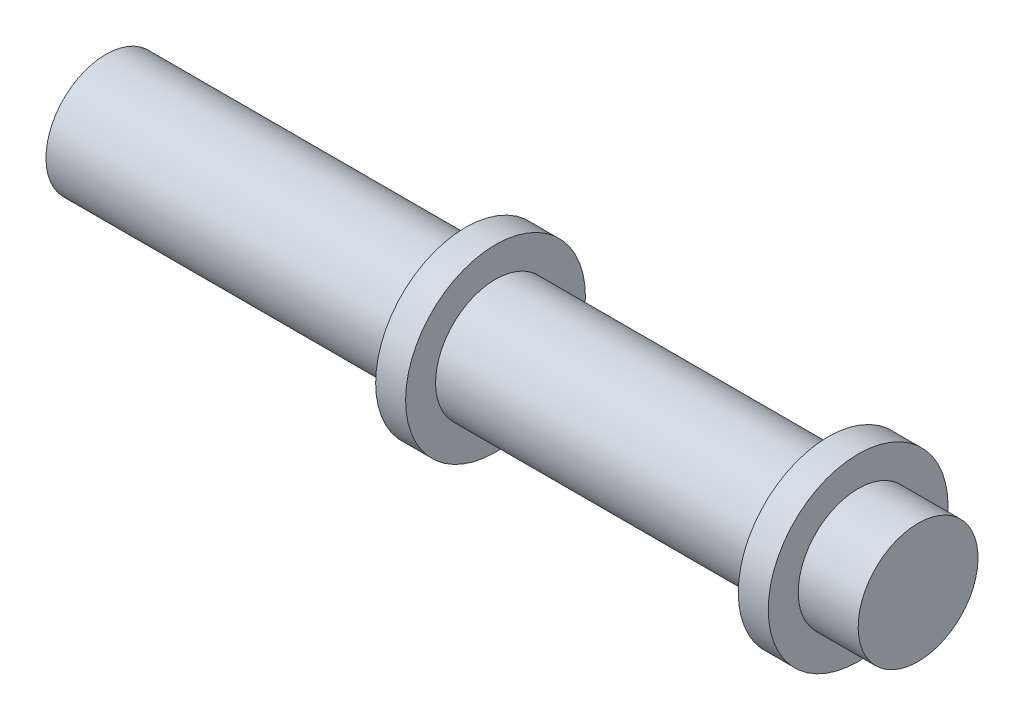
from build123d import *


with BuildPart() as part:
    # Sketch2 → Revolve1 (revolve)
    with BuildSketch(Plane.XY):
        Polygon((-27.1, 4), (-3.1, 4), (-3.1, 6), (-1.1, 6), (-1.1, 4), (21.1, 4), (21.1, 6), (23.1, 6), (23.1, 4), (27.1, 4), (27.1, 0), (-27.1, 0), align=None)
    revolve(axis=Axis((27.1, 0, 0), (-1, 0, 0)))


solid = part.part
